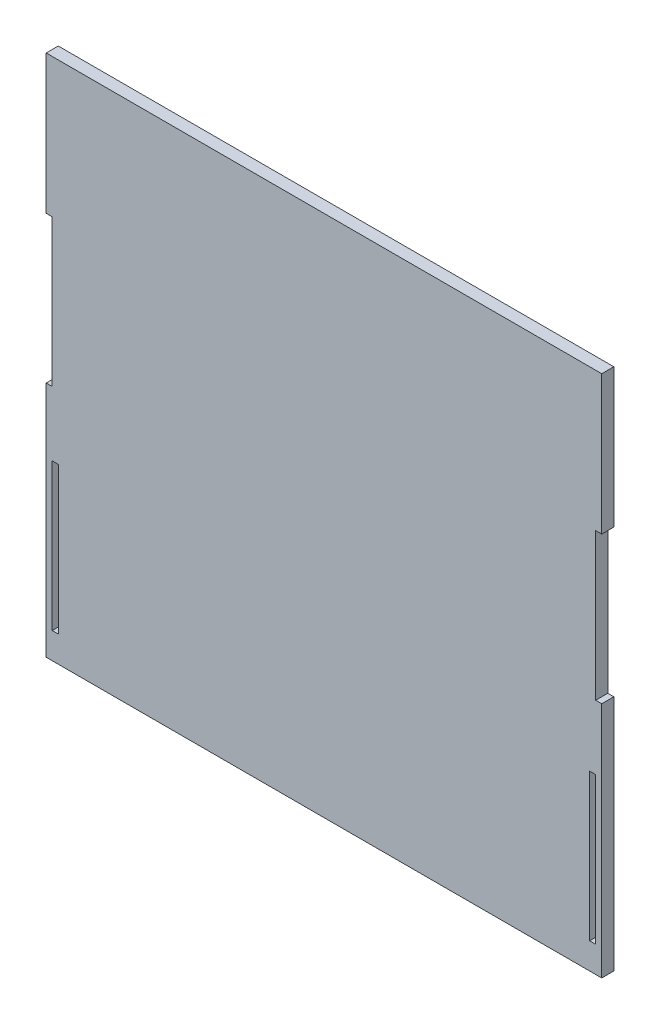
from build123d import *

# Parameters (mm, degrees)
SKETCH1_W           = 1.5
SKETCH1_H           = 36.5
BOSS_EXTRUDE1_DEPTH = 3


with BuildPart() as part:
    # Sketch1 → Boss-Extrude1 (new body)
    with BuildSketch(Plane.XY):
        Polygon((0, 59), (0, 0), (138, 0), (138, 59), (136.5, 59), (136.5, 95.5), (138, 95.5), (138, 130), (0, 130), (0, 95.5), (1.5, 95.5), (1.5, 59), align=None)
        with Locations((2.25, 24.75)):
            Rectangle(SKETCH1_W, SKETCH1_H, mode=Mode.SUBTRACT)
        with Locations((135.75, 24.75)):
            Rectangle(SKETCH1_W, SKETCH1_H, mode=Mode.SUBTRACT)
    extrude(amount=BOSS_EXTRUDE1_DEPTH)


solid = part.part
